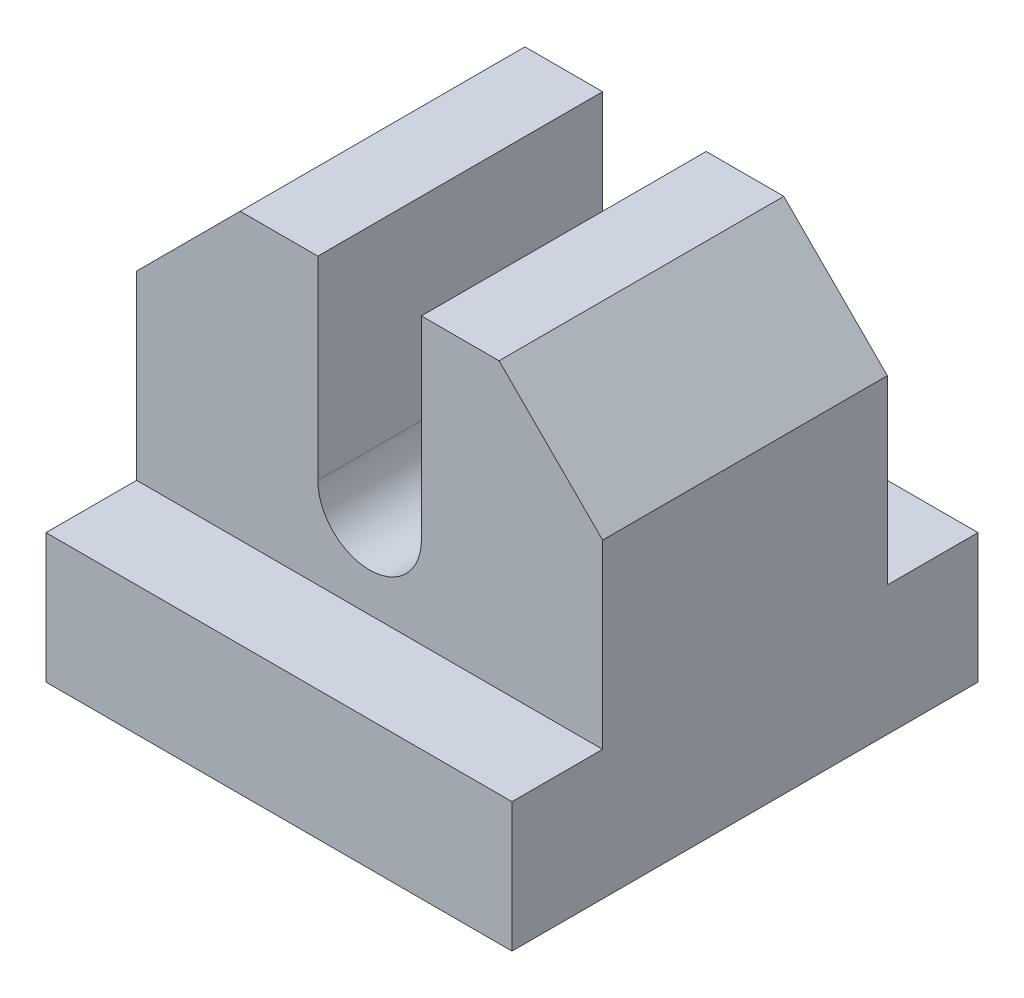
from build123d import *

# Parameters (mm, degrees)
SKETCH1_W           = 18
SKETCH1_H           = 18
BOSS_EXTRUDE1_DEPTH = 5
SKETCH4_W           = 12
SKETCH4_H           = 12
CUT_EXTRUDE1_DEPTH  = 3
SKETCH5_W           = 18
SKETCH5_H           = 11
BOSS_EXTRUDE2_DEPTH = 11
CUT_EXTRUDE2_DEPTH  = 15.5


with BuildPart() as part:
    # Sketch1 → Boss-Extrude1 (new body)
    with BuildSketch(Plane(origin=(0, 0, 0), x_dir=(1, 0, 0), z_dir=(0, 1, 0))):
        with Locations((-259.2, 371.7)):
            Rectangle(SKETCH1_W, SKETCH1_H)
    extrude(amount=BOSS_EXTRUDE1_DEPTH)

    # Sketch4 → Cut-Extrude1 (cut)
    with BuildSketch(Plane.XZ):
        with Locations((-259.2, -371.7)):
            Rectangle(SKETCH4_W, SKETCH4_H)
    extrude(amount=-CUT_EXTRUDE1_DEPTH, mode=Mode.SUBTRACT)

    # Sketch5 → Boss-Extrude2 (add)
    with BuildSketch(Plane(origin=(0, 5, 0), x_dir=(1, 0, 0), z_dir=(0, 1, 0))):
        with Locations((-259.2, 371.7)):
            Rectangle(SKETCH5_W, SKETCH5_H)
    extrude(amount=BOSS_EXTRUDE2_DEPTH)

    # Sketch7 → Cut-Extrude2 (cut, through all)
    with BuildSketch(Plane.XY.offset(-366.2)):
        with BuildLine():
            ThreePointArc((-261.2, 8.5), (-259.2, 6.5), (-257.2, 8.5))
            Line((-257.2, 8.5), (-261.2, 8.5))
        make_face()
        with BuildLine():
            Line((-261.2, 8.5), (-257.2, 8.5))
            ThreePointArc((-257.2, 8.5), (-259.2, 10.5), (-261.2, 8.5))
        make_face()
        with BuildLine():
            Line((-257.2, 16), (-259.2, 16))
            Line((-259.2, 16), (-261.2, 16))
            Line((-261.2, 16), (-261.2, 8.5))
            ThreePointArc((-261.2, 8.5), (-259.2, 10.5), (-257.2, 8.5))
            Line((-257.2, 8.5), (-257.2, 16))
        make_face()
        Polygon((-250.2, 16), (-254.2, 16), (-250.2, 12), align=None)
        Polygon((-268.2, 12), (-264.2, 16), (-268.2, 16), align=None)
    extrude(amount=-CUT_EXTRUDE2_DEPTH, mode=Mode.SUBTRACT)


solid = part.part
